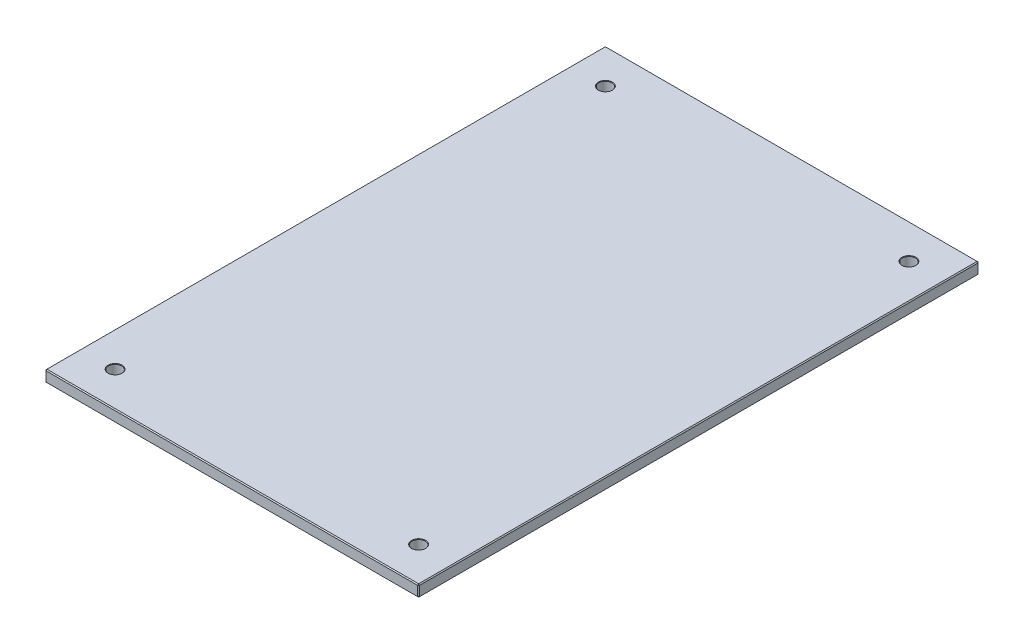
from build123d import *

# Parameters (mm, degrees)
SKETCH1_W                        = 203.2
SKETCH1_H                        = 304.8
BOSS_EXTRUDE1_DEPTH              = 3.175
F_1_4_CLEARANCE_HOLE1_AT_2_COUNT = 2
F_1_4_CLEARANCE_HOLE1_AT_2_PITCH = 165.1
F_1_4_CLEARANCE_HOLE1_AT_3_COUNT = 2
F_1_4_CLEARANCE_HOLE1_AT_3_PITCH = 313.666861495
F_1_4_CLEARANCE_HOLE1_AT_4_COUNT = 2
F_1_4_CLEARANCE_HOLE1_AT_4_PITCH = 266.7
CHAMFER1_SIZE                    = 0.508


with BuildPart() as part:
    # Sketch1 → Boss-Extrude1 (new, symmetric)
    with BuildSketch(Plane(origin=(0, 0, 0), x_dir=(1, 0, 0), z_dir=(0, 1, 0))):
        Rectangle(SKETCH1_W, SKETCH1_H)
    extrude(amount=BOSS_EXTRUDE1_DEPTH, both=True)

    # Sketch4 → 1_4 Clearance Hole1 (revolve, cut)
    with BuildSketch(Plane(origin=(-82.55, 3.175, -133.35), x_dir=(0, 0, 1), z_dir=(1, 0, 0))):
        Polygon((0, 0), (0, 6.35), (3.82524, 6.35), (3.57124, 6.096), (3.57124, 0.254), (3.82524, 0), align=None)
    f_1_4_clearance_hole1 = revolve(axis=Axis((-82.55, 9.525, -133.35), (0, -1, 0)), mode=Mode.SUBTRACT)

    # 1_4 Clearance Hole1 at 2: 1_4 Clearance Hole1 ×2
    with Locations(*[(i * F_1_4_CLEARANCE_HOLE1_AT_2_PITCH, 0, 0) for i in range(1, F_1_4_CLEARANCE_HOLE1_AT_2_COUNT)]):
        add(f_1_4_clearance_hole1, mode=Mode.SUBTRACT)

    # 1_4 Clearance Hole1 at 3: 1_4 Clearance Hole1 ×2
    with Locations(*[Vector(0.5263546146162954, 0, 0.8502651466878619) * (i * F_1_4_CLEARANCE_HOLE1_AT_3_PITCH) for i in range(1, F_1_4_CLEARANCE_HOLE1_AT_3_COUNT)]):
        add(f_1_4_clearance_hole1, mode=Mode.SUBTRACT)

    # 1_4 Clearance Hole1 at 4: 1_4 Clearance Hole1 ×2
    with Locations(*[(0, 0, i * F_1_4_CLEARANCE_HOLE1_AT_4_PITCH) for i in range(1, F_1_4_CLEARANCE_HOLE1_AT_4_COUNT)]):
        add(f_1_4_clearance_hole1, mode=Mode.SUBTRACT)

    # Chamfer1
    chamfer1_edges = [part.edges().sort_by_distance(p)[0] for p in [
        (101.6, 3.175, 0),
        (101.6, -3.175, 0),
        (101.6, 0, -152.4),
        (0, 3.175, -152.4),
        (0, -3.175, -152.4),
        (-101.6, 0, -152.4),
        (-101.6, 3.175, 0),
        (-101.6, -3.175, 0),
        (-101.6, 0, 152.4),
        (0, 3.175, 152.4),
        (101.6, 0, 152.4),
        (0, -3.175, 152.4),
    ]]
    chamfer(chamfer1_edges, length=CHAMFER1_SIZE)


solid = part.part
